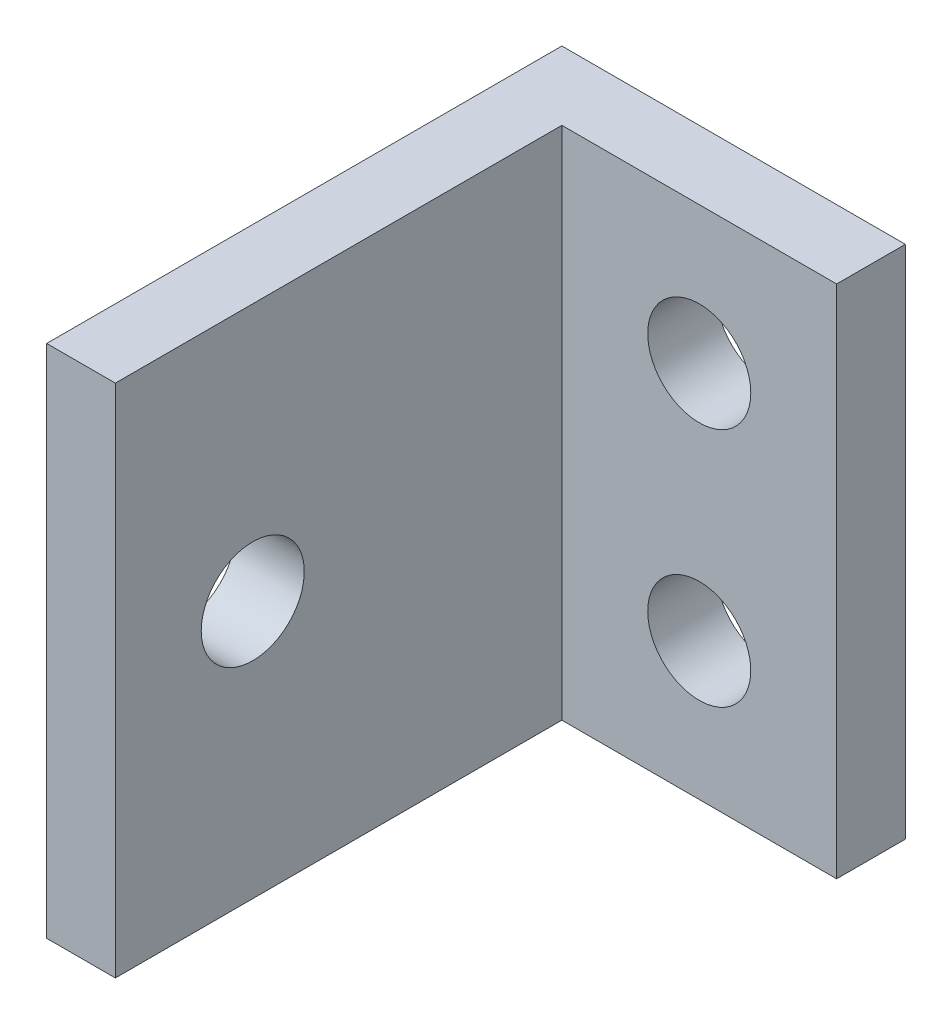
from build123d import *

# Parameters (mm, degrees)
BOSS_EXTRUDE1_DEPTH             = 15
SKETCH3_R                       = 1.5
CUT_EXTRUDE1_DEPTH              = 3
SKETCH4_R                       = 1.5
SCHNITT_LINEAR_AUSTRAGEN1_DEPTH = 10


with BuildPart() as part:
    # Sketch1 → Boss-Extrude1 (new body)
    with BuildSketch(Plane(origin=(0, 0, 0), x_dir=(1, 0, 0), z_dir=(0, 1, 0))):
        Polygon((4.45631068, 12.597087379), (-5.54368932, 12.597087379), (-5.54368932, -2.402912621), (-3.54368932, -2.402912621), (-3.54368932, 10.597087379), (4.45631068, 10.597087379), align=None)
    extrude(amount=BOSS_EXTRUDE1_DEPTH)

    # Sketch3 → Cut-Extrude1 (cut, through all)
    with BuildSketch(Plane.XY.offset(-10.597087379)):
        with Locations((0.45631068, 11)):
            Circle(SKETCH3_R)
        with Locations((0.45631068, 4)):
            Circle(SKETCH3_R)
    extrude(amount=-CUT_EXTRUDE1_DEPTH, mode=Mode.SUBTRACT)

    # Sketch4 → Schnitt-Linear austragen1 (cut)
    with BuildSketch(Plane.ZY.offset(5.54368932)):
        with Locations((-1.597087379, 7.5)):
            Circle(SKETCH4_R)
    extrude(amount=-SCHNITT_LINEAR_AUSTRAGEN1_DEPTH, mode=Mode.SUBTRACT)


solid = part.part
